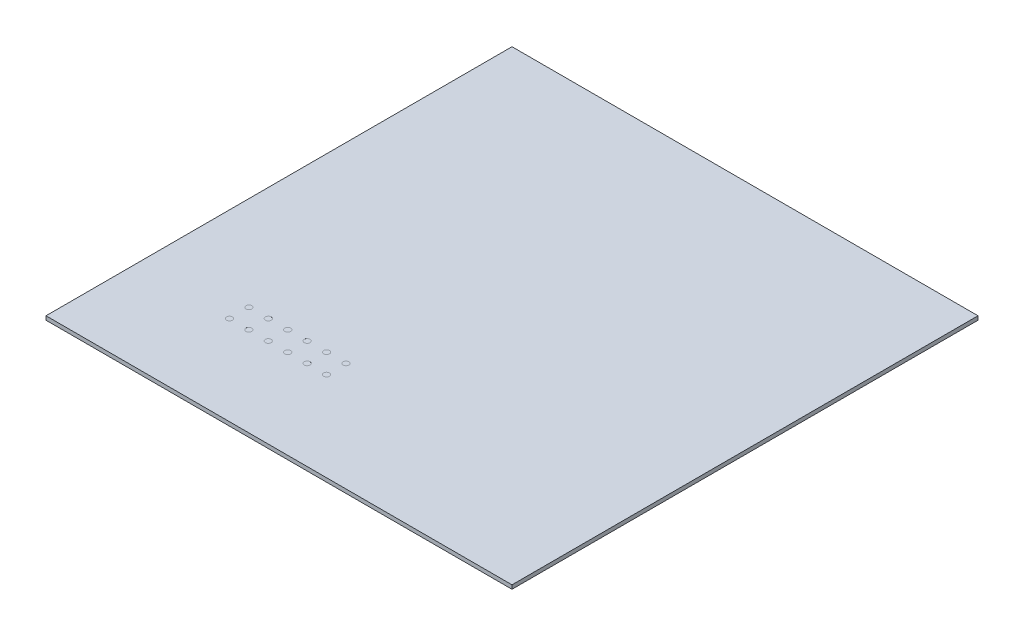
from build123d import *

# Parameters (mm, degrees)
SKETCH1_W           = 12000
SKETCH1_H           = 12000
BOSS_EXTRUDE1_DEPTH = 100
SKETCH5_R           = 75
CUT_EXTRUDE2_DEPTH  = 0.1


with BuildPart() as part:
    # Sketch1 → Boss-Extrude1 (new body)
    with BuildSketch(Plane(origin=(0, 0, 0), x_dir=(1, 0, 0), z_dir=(0, 1, 0))):
        with Locations((6000, 6000)):
            Rectangle(SKETCH1_W, SKETCH1_H)
    extrude(amount=BOSS_EXTRUDE1_DEPTH)

    # Sketch5 → Cut-Extrude2 (cut)
    with BuildSketch(Plane(origin=(0, 100, 0), x_dir=(1, 0, 0), z_dir=(0, 1, 0))):
        with Locations((2425, 2800)):
            Circle(SKETCH5_R)
        with Locations((2425, 2300)):
            Circle(SKETCH5_R)
        with Locations((2925, 2300)):
            Circle(SKETCH5_R)
        with Locations((3425, 2300)):
            Circle(SKETCH5_R)
        with Locations((3925, 2300)):
            Circle(SKETCH5_R)
        with Locations((4425, 2300)):
            Circle(SKETCH5_R)
        with Locations((4925, 2300)):
            Circle(SKETCH5_R)
        with Locations((2925, 2800)):
            Circle(SKETCH5_R)
        with Locations((3425, 2800)):
            Circle(SKETCH5_R)
        with Locations((3925, 2800)):
            Circle(SKETCH5_R)
        with Locations((4425, 2800)):
            Circle(SKETCH5_R)
        with Locations((4925, 2800)):
            Circle(SKETCH5_R)
    extrude(amount=-CUT_EXTRUDE2_DEPTH, mode=Mode.SUBTRACT)


solid = part.part
